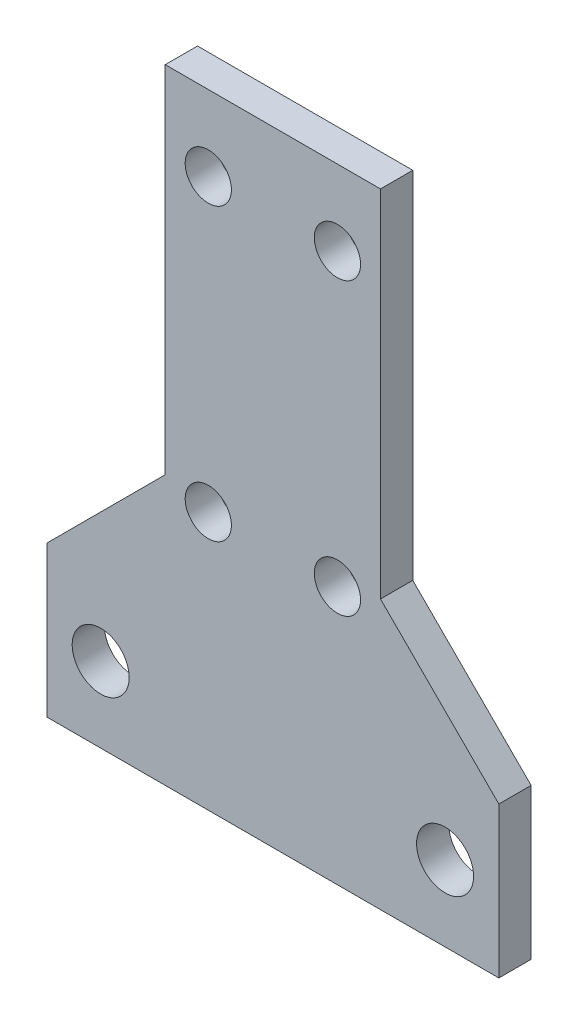
from build123d import *

# Parameters (mm, degrees)
SKETCH2_R           = 2.65
SKETCH2_R_2         = 2.15
BOSS_EXTRUDE1_DEPTH = 3


with BuildPart() as part:
    # Sketch2 → Boss-Extrude1 (new body)
    with BuildSketch(Plane.XY):
        Polygon((-434.489921235, 165), (-392.489921235, 165), (-392.489921235, 179), (-403.489921235, 190), (-403.489921235, 223), (-423.489921235, 223), (-423.489921235, 190), (-434.489921235, 179), align=None)
        with Locations((-397.489921235, 172)):
            Circle(SKETCH2_R, mode=Mode.SUBTRACT)
        with Locations((-407.489921235, 216)):
            Circle(SKETCH2_R_2, mode=Mode.SUBTRACT)
        with Locations((-407.489921235, 189)):
            Circle(SKETCH2_R_2, mode=Mode.SUBTRACT)
        with Locations((-429.489921235, 172)):
            Circle(SKETCH2_R, mode=Mode.SUBTRACT)
        with Locations((-419.489921235, 189)):
            Circle(SKETCH2_R_2, mode=Mode.SUBTRACT)
        with Locations((-419.489921235, 216)):
            Circle(SKETCH2_R_2, mode=Mode.SUBTRACT)
    extrude(amount=BOSS_EXTRUDE1_DEPTH)


solid = part.part
